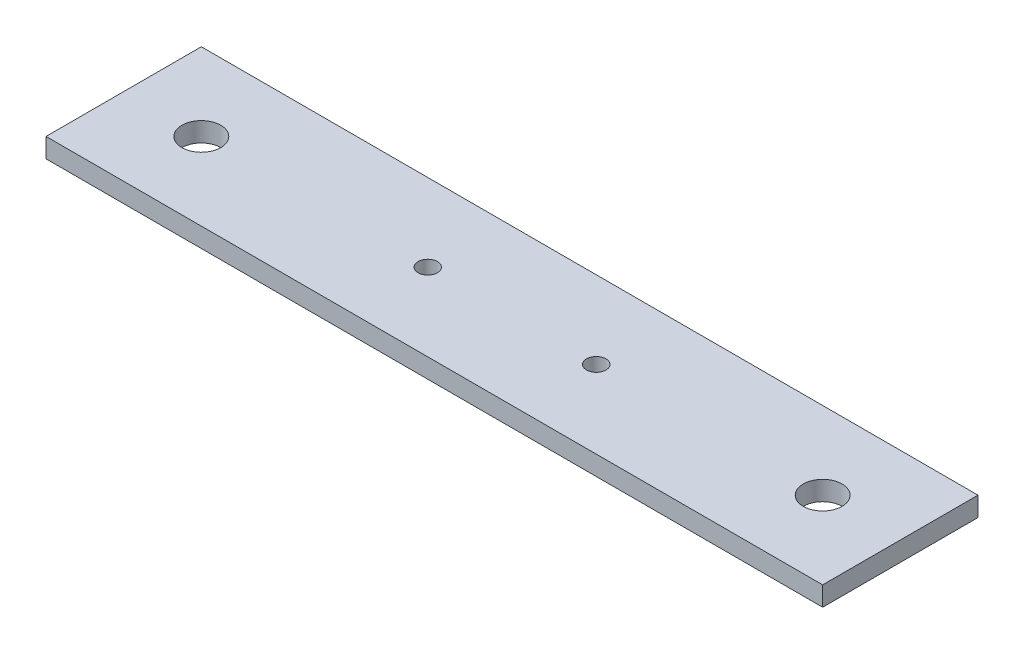
from build123d import *

# Parameters (mm, degrees)
SKETCH1_W           = 127
SKETCH1_H           = 25.4
SKETCH1_R           = 3.175
SKETCH1_R_2         = 1.5875
BOSS_EXTRUDE1_DEPTH = 3.175


with BuildPart() as part:
    # Sketch1 → Boss-Extrude1 (new body)
    with BuildSketch(Plane(origin=(0, 0, 0), x_dir=(1, 0, 0), z_dir=(0, 1, 0))):
        Rectangle(SKETCH1_W, SKETCH1_H)
        with Locations((-50.8, 0)):
            Circle(SKETCH1_R, mode=Mode.SUBTRACT)
        with Locations((50.8, 0)):
            Circle(SKETCH1_R, mode=Mode.SUBTRACT)
        with Locations((-13.774801, 0)):
            Circle(SKETCH1_R_2, mode=Mode.SUBTRACT)
        with Locations((13.774801, 0)):
            Circle(SKETCH1_R_2, mode=Mode.SUBTRACT)
    extrude(amount=BOSS_EXTRUDE1_DEPTH)


solid = part.part
